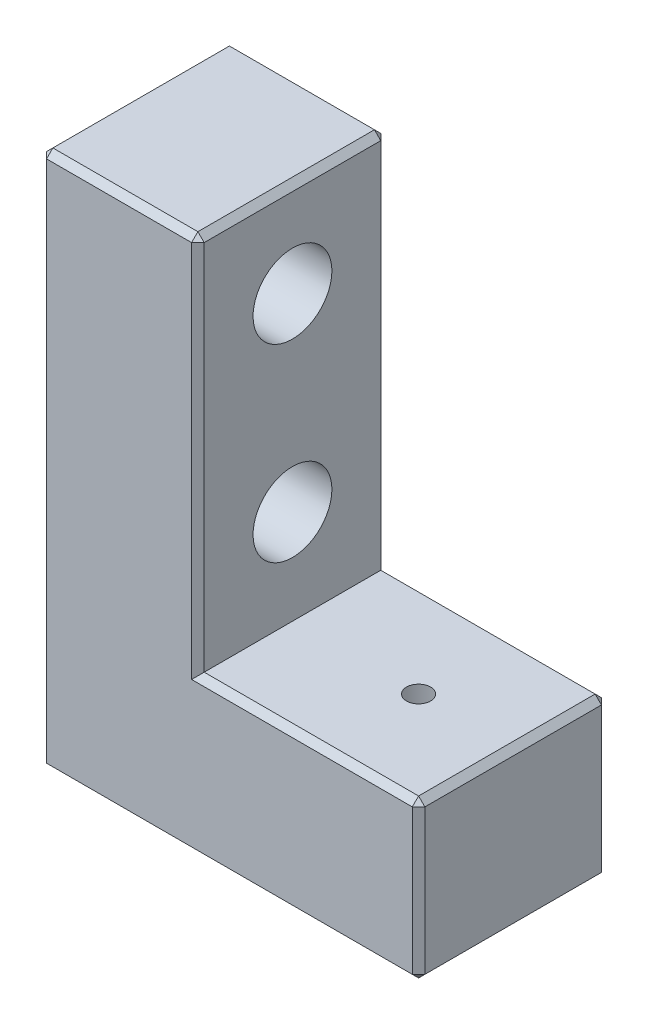
from build123d import *

# Parameters (mm, degrees)
EXTRUDE_1_DEPTH        = 3
SKETCH_2_R             = 1.25
CUT_EXTRUDE_1_DEPTH    = 6
SKETCH_3_R             = 1.25
CUT_EXTRUDE_2_DEPTH    = 3
HOLE_WIZARD_M3_1_D     = 2.5
HOLE_WIZARD_M3_1_DEPTH = 4.5
HOLE_WIZARD_M3_1_TIP   = 0.721687836
CHAMFER_1_SIZE         = 0.2
CHAMFER_2_SIZE         = 0.2


with BuildPart() as part:
    # 草图1 → 凸台-拉伸1 (new body, symmetric)
    with BuildSketch(Plane.XY):
        Polygon((0, 17), (0, 0), (12, 0), (12, 5), (5, 5), (5, 17), align=None)
    extrude(amount=EXTRUDE_1_DEPTH, both=True)

    # 草图2 → 切除-拉伸1 (cut)
    with BuildSketch(Plane(origin=(5, 0, 0), x_dir=(0, 0, -1), z_dir=(1, 0, 0))):
        with Locations((0, 14)):
            Circle(SKETCH_2_R)
        with Locations((0, 8)):
            Circle(SKETCH_2_R)
    extrude(amount=-CUT_EXTRUDE_1_DEPTH, mode=Mode.SUBTRACT)

    # 草图3 → 切除-拉伸2 (cut)
    with BuildSketch(Plane.XZ):
        with Locations((9, 0)):
            Circle(SKETCH_3_R)
        with Locations((3, 0)):
            Circle(SKETCH_3_R)
    extrude(amount=-CUT_EXTRUDE_2_DEPTH, mode=Mode.SUBTRACT)

    # M3 螺纹孔1
    with Locations(Plane(origin=(3, 0, 0), x_dir=(0, 0, -1), z_dir=(0, -1, 0))):
        with Locations((0, 0), (0, 6)):
            Hole(HOLE_WIZARD_M3_1_D / 2, depth=HOLE_WIZARD_M3_1_DEPTH)
            with Locations((0, 0, -(HOLE_WIZARD_M3_1_DEPTH + HOLE_WIZARD_M3_1_TIP / 2))):  # 120° drill point
                Cone(0, HOLE_WIZARD_M3_1_D / 2, HOLE_WIZARD_M3_1_TIP, mode=Mode.SUBTRACT)

    # 倒角1
    chamfer_1_edges = [part.edges().sort_by_distance(p)[0] for p in [
        (6, 0, 3),
        (5, 17, 0),
        (12, 5, 0),
        (12, 0, 0),
        (0, 17, 0),
        (12, 2.5, 3),
        (8.5, 5, 3),
        (5, 11, 3),
        (2.5, 17, 3),
        (5, 11, -3),
        (8.5, 5, -3),
        (12, 2.5, -3),
        (0, 8.5, 3),
        (6, 0, -3),
        (0, 8.5, -3),
        (2.5, 17, -3),
    ]]
    chamfer(chamfer_1_edges, length=CHAMFER_1_SIZE)

    # 倒角2
    chamfer_2_edges = [part.edges().sort_by_distance(p)[0] for p in [
        (0, 0, 0),
    ]]
    chamfer(chamfer_2_edges, length=CHAMFER_2_SIZE)


solid = part.part
